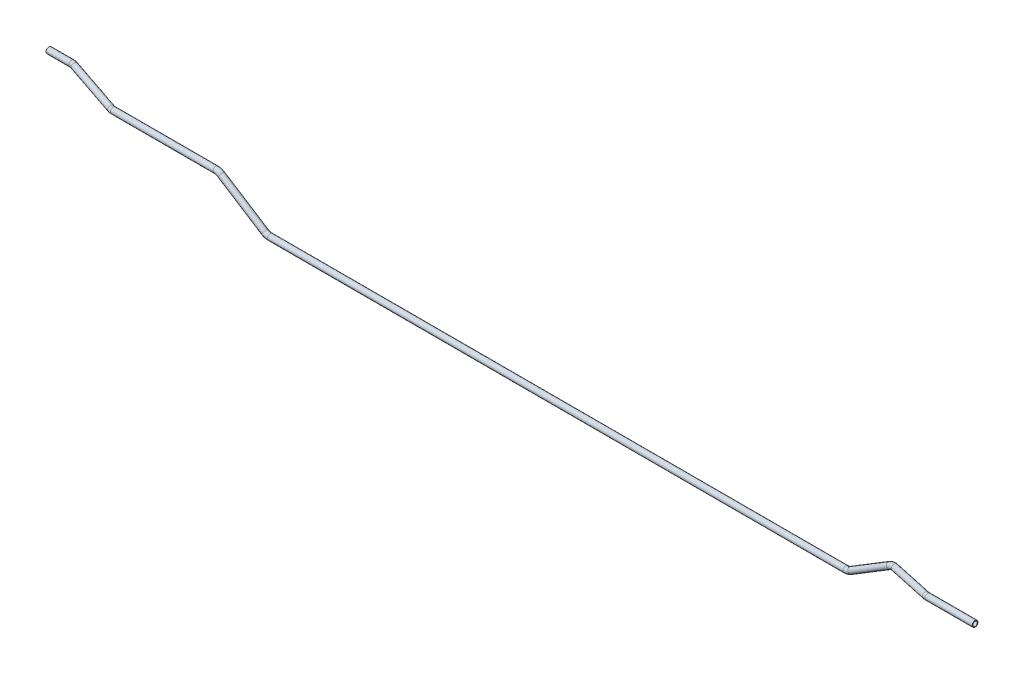
from build123d import *

# Parameters (mm, degrees)
SKETCH1_R   = 6
SKETCH1_R_2 = 4.5


with BuildPart() as part:
    # Sweep1: sweep along a curve in space
    with BuildLine() as sweep1_path:
        Line((0, 0, 0), (47.016462702, 0, 0))
        ThreePointArc((47.016462702, 0, 0), (49.970337259, -0.15118907, 0.14398959), (52.865476157, -0.601749993, 0.573095231))
        Line((147.134523843, -20.398250007, 19.426904769), (52.865476157, -0.601749993, 0.573095231))
        ThreePointArc((152.983537298, -21, 20), (150.029662741, -20.84881093, 19.85601041), (147.134523843, -20.398250007, 19.426904769))
        Line((152.983537298, -21, 20), (363.855342041, -21, 20))
        ThreePointArc((363.855342041, -21, 20), (369.752727576, -21.845078917, 20), (375.175469666, -24.312300586, 20))
        Line((375.175469666, -24.312300586, 20), (464.824530334, -81.687699414, 20))
        ThreePointArc((476.144657959, -85, 20), (470.247272424, -84.154921083, 20), (464.824530334, -81.687699414, 20))
        Line((476.144657959, -85, 20), (1662.091319518, -85, 20))
        ThreePointArc((1662.091319518, -85, 20), (1667.779144733, -84.21505984, 20), (1673.041769716, -81.918918507, 20))
        Line((1673.041769716, -81.918918507, 20), (1752.607836624, -33.295210952, 20))
        ThreePointArc((1764.176020435, -30, 21.338137761), (1758.200210383, -30.841652746, 20.341783072), (1752.607836624, -33.295210952, 20))
        Line((1764.176020435, -30, 21.338137761), (1845.802088956, -30, 39.023785941))
        ThreePointArc((1850.248909244, -30, 39.5), (1848.012785896, -30, 39.380607088), (1845.802088956, -30, 39.023785941))
        Line((1850.248909244, -30, 39.5), (1948, -30, 39.5))
    # Sketch1 → Sweep1 (sweep)
    with BuildSketch(Plane(origin=(0, 0, 0), x_dir=(0, 0, -1), z_dir=(1, 0, 0))):
        Circle(SKETCH1_R)
        Circle(SKETCH1_R_2, mode=Mode.SUBTRACT)
    sweep(path=sweep1_path.line)


solid = part.part
